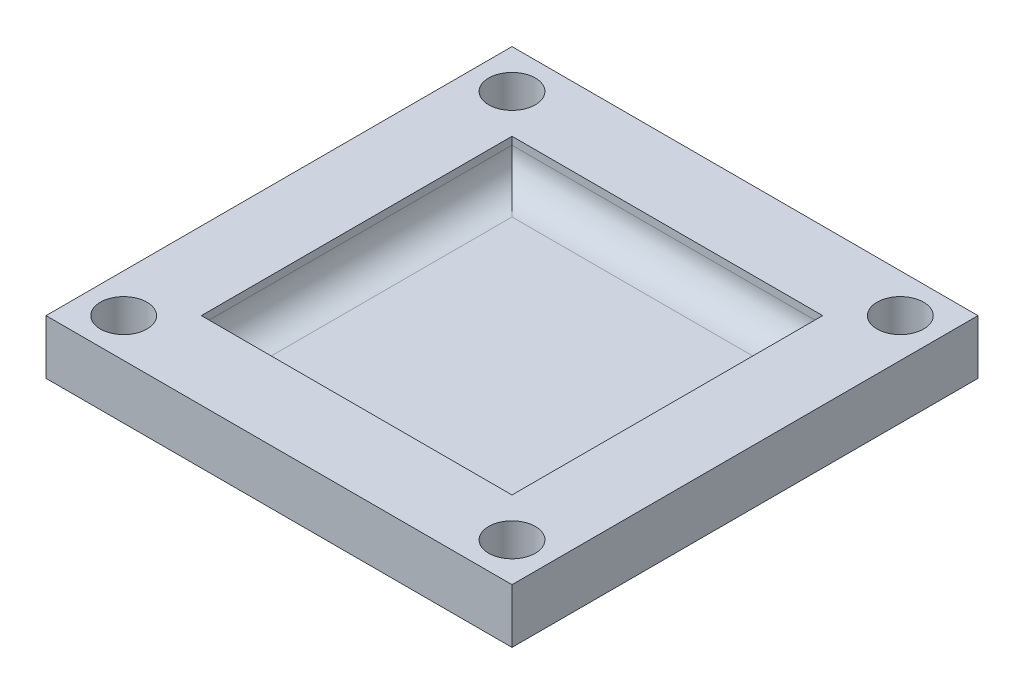
from build123d import *

# Parameters (mm, degrees)
SKETCH2_W           = 30
SKETCH2_H           = 30
SKETCH2_W_2         = 20
SKETCH2_H_2         = 20
BOSS_EXTRUDE2_DEPTH = 3.5
SKETCH2_4_W         = 20
SKETCH2_4_H         = 20
BOSS_EXTRUDE3_DEPTH = 1
FILLET1_R           = 2
CUT_EXTRUDE1_DEPTH  = 4


with BuildPart() as part:
    # Sketch2 → Boss-Extrude2 (new body)
    with BuildSketch(Plane(origin=(0, 0, 0), x_dir=(1, 0, 0), z_dir=(0, 1, 0))):
        Rectangle(SKETCH2_W, SKETCH2_H)
        Rectangle(SKETCH2_W_2, SKETCH2_H_2, mode=Mode.SUBTRACT)
    extrude(amount=BOSS_EXTRUDE2_DEPTH)

    # Sketch2_4 → Boss-Extrude3 (add)
    with BuildSketch(Plane(origin=(0, 0, 0), x_dir=(1, 0, 0), z_dir=(0, 1, 0))):
        Rectangle(SKETCH2_4_W, SKETCH2_4_H)
    extrude(amount=BOSS_EXTRUDE3_DEPTH)

    # Fillet1
    fillet1_edges = [part.edges().sort_by_distance(p)[0] for p in [
        (-10, 1, 0),
        (0, 1, -10),
        (0, 1, 10),
        (10, 1, 0),
    ]]
    fillet(fillet1_edges, radius=FILLET1_R)

    # Sketch6 → Cut-Extrude1 (cut)
    with BuildSketch(Plane(origin=(0, 3.5, 0), x_dir=(1, 0, 0), z_dir=(0, 1, 0))):
        with BuildLine():
            ThreePointArc((-13.560660172, 13.560660172), (-13.560660172, 11.439339828), (-11.439339828, 11.439339828))
            Line((-11.439339828, 11.439339828), (-13.560660172, 13.560660172))
        make_face()
        with BuildLine():
            Line((-13.560660172, 13.560660172), (-11.439339828, 11.439339828))
            ThreePointArc((-11.439339828, 11.439339828), (-11.114180701, 11.925974851), (-11, 12.5))
            ThreePointArc((-11, 12.5), (-11.925974851, 13.885819299), (-13.560660172, 13.560660172))
        make_face()
        with BuildLine():
            ThreePointArc((13.560660172, 13.560660172), (11.439339828, 13.560660172), (11.439339828, 11.439339828))
            Line((11.439339828, 11.439339828), (13.560660172, 13.560660172))
        make_face()
        with BuildLine():
            Line((13.560660172, 13.560660172), (11.439339828, 11.439339828))
            ThreePointArc((11.439339828, 11.439339828), (13.074025149, 11.114180701), (14, 12.5))
            ThreePointArc((14, 12.5), (13.885819299, 13.074025149), (13.560660172, 13.560660172))
        make_face()
        with BuildLine():
            ThreePointArc((14, -12.5), (13.074025149, -11.114180701), (11.439339828, -11.439339828))
            Line((11.439339828, -11.439339828), (13.560660172, -13.560660172))
            ThreePointArc((13.560660172, -13.560660172), (13.885819299, -13.074025149), (14, -12.5))
        make_face()
        with BuildLine():
            Line((13.560660172, -13.560660172), (11.439339828, -11.439339828))
            ThreePointArc((11.439339828, -11.439339828), (11.439339828, -13.560660172), (13.560660172, -13.560660172))
        make_face()
        with BuildLine():
            ThreePointArc((-11, -12.5), (-11.114180701, -11.925974851), (-11.439339828, -11.439339828))
            Line((-11.439339828, -11.439339828), (-13.560660172, -13.560660172))
            ThreePointArc((-13.560660172, -13.560660172), (-11.925974851, -13.885819299), (-11, -12.5))
        make_face()
        with BuildLine():
            Line((-13.560660172, -13.560660172), (-11.439339828, -11.439339828))
            ThreePointArc((-11.439339828, -11.439339828), (-13.560660172, -11.439339828), (-13.560660172, -13.560660172))
        make_face()
    extrude(amount=-CUT_EXTRUDE1_DEPTH, mode=Mode.SUBTRACT)


solid = part.part
